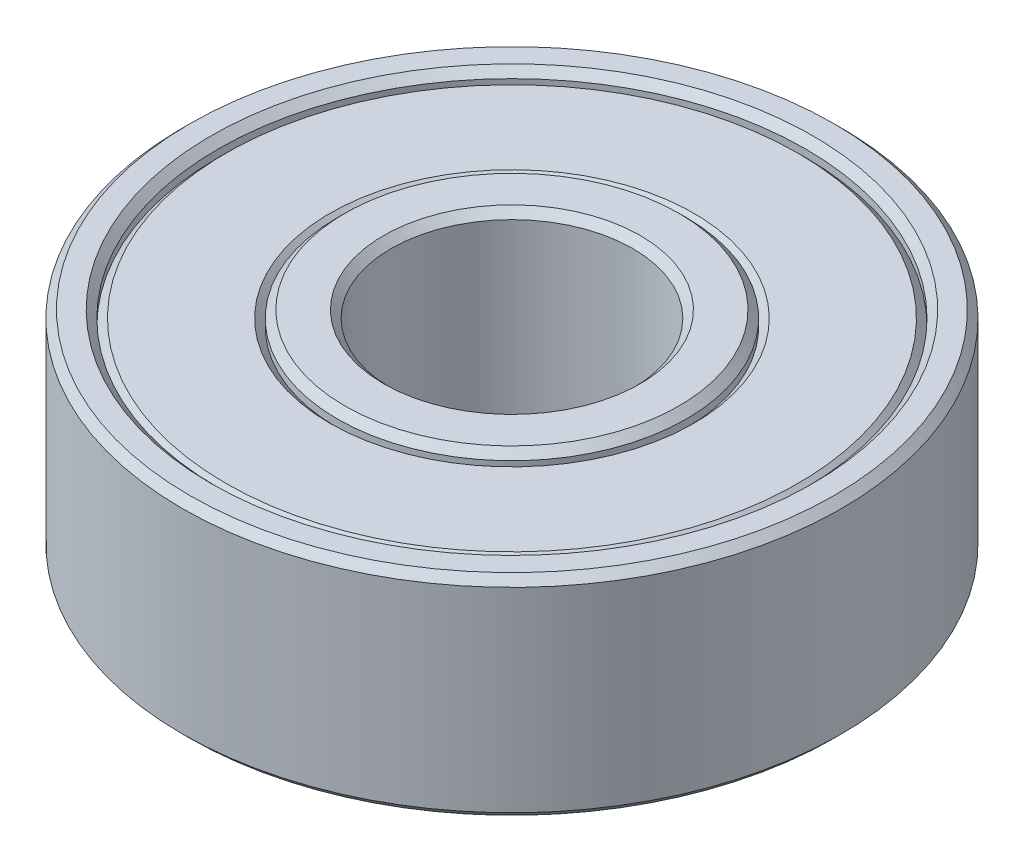
from build123d import *

# Parameters (mm, degrees)
SKETCH1_R             = 10.975
SKETCH1_R_2           = 9.775
BOSS_EXTRUDE1_DEPTH   = 3.5
SKETCH1_R_3           = 5.81
SKETCH1_R_4           = 4.025
BOSS_EXTRUDE1_2_DEPTH = 3.5
SKETCH1_3_R           = 9.775
SKETCH1_3_R_2         = 5.81
BOSS_EXTRUDE2_DEPTH   = 3.25
CHAMFER1_SIZE         = 0.25
CHAMFER2_SIZE         = 0.25
CHAMFER3_SIZE         = 0.25


with BuildPart() as part:
    # Sketch1 → Boss-Extrude1 (new, symmetric)
    with BuildSketch(Plane(origin=(0, 0, 0), x_dir=(1, 0, 0), z_dir=(0, 1, 0))):
        Circle(SKETCH1_R)
        Circle(SKETCH1_R_2, mode=Mode.SUBTRACT)
    extrude(amount=BOSS_EXTRUDE1_DEPTH, both=True)

    # Chamfer2
    chamfer2_edges = [part.edges().sort_by_distance(p)[0] for p in [
        (-9.775, -3.5, 0),
        (-9.775, 3.5, 0),
        (-10.975, -3.5, 0),
        (-10.975, 3.5, 0),
    ]]
    chamfer(chamfer2_edges, length=CHAMFER2_SIZE)


with BuildPart() as body_2:
    # Sketch1 → Boss-Extrude1 2 (new, symmetric)
    with BuildSketch(Plane(origin=(0, 0, 0), x_dir=(1, 0, 0), z_dir=(0, 1, 0))):
        Circle(SKETCH1_R_3)
        Circle(SKETCH1_R_4, mode=Mode.SUBTRACT)
    extrude(amount=BOSS_EXTRUDE1_2_DEPTH, both=True)

    # Chamfer3
    chamfer3_edges = [body_2.edges().sort_by_distance(p)[0] for p in [
        (-5.81, 3.5, 0),
        (-4.025, 3.5, 0),
        (-4.025, -3.5, 0),
        (-5.81, -3.5, 0),
    ]]
    chamfer(chamfer3_edges, length=CHAMFER3_SIZE)


with BuildPart() as body_3:
    # Sketch1_3 → Boss-Extrude2 (new, symmetric)
    with BuildSketch(Plane(origin=(0, 0, 0), x_dir=(1, 0, 0), z_dir=(0, 1, 0))):
        Circle(SKETCH1_3_R)
        Circle(SKETCH1_3_R_2, mode=Mode.SUBTRACT)
    extrude(amount=BOSS_EXTRUDE2_DEPTH, both=True)

    # Chamfer1
    chamfer1_edges = [body_3.edges().sort_by_distance(p)[0] for p in [
        (-5.81, -3.25, 0),
        (-9.775, -3.25, 0),
        (-5.81, 3.25, 0),
        (-9.775, 3.25, 0),
    ]]
    chamfer(chamfer1_edges, length=CHAMFER1_SIZE)

    # Combine1: union body 2, part
    add(body_2.part)
    add(part.part)


solid = body_3.part
